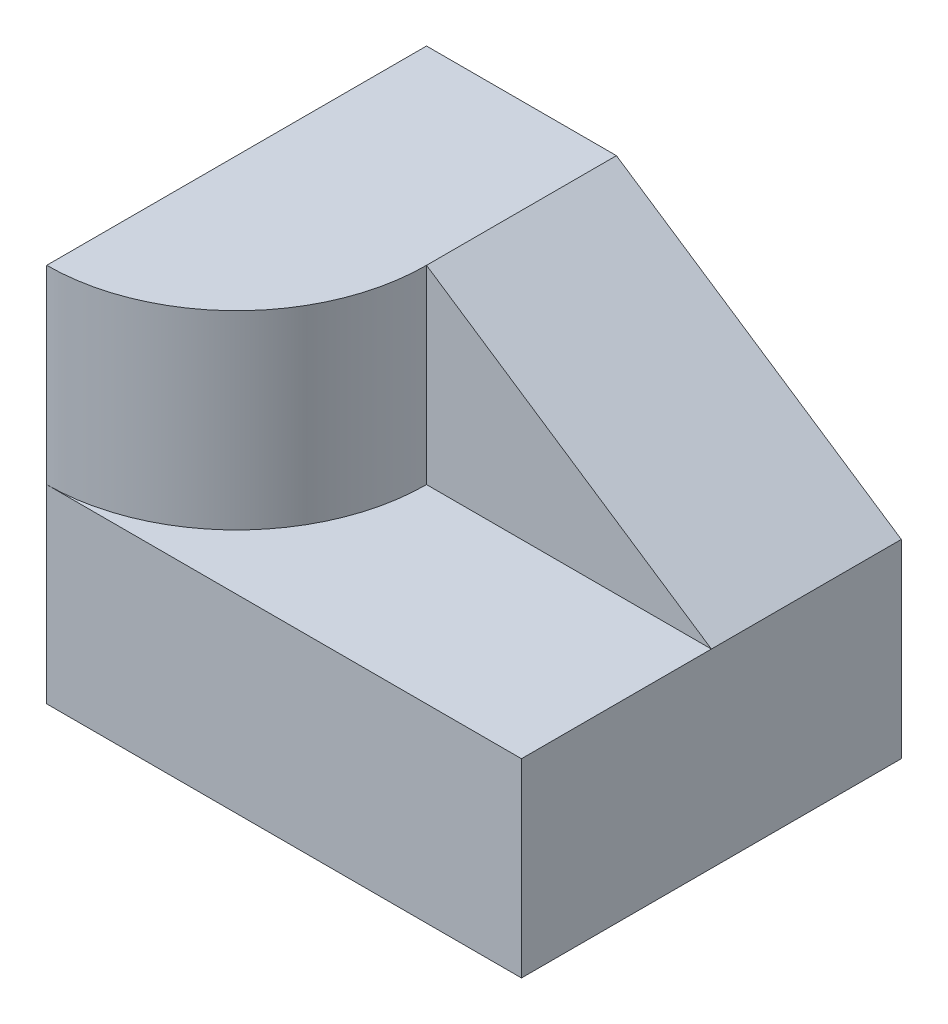
from build123d import *

# Parameters (mm, degrees)
SKETCH_1_W          = 25
SKETCH_1_H          = 20
EXTRUDE_1_DEPTH     = 10
EXTRUDE_2_DEPTH     = 20
CUT_EXTRUDE_1_DEPTH = 20
SCALE_1_SCALE       = 0.2


with BuildPart() as part:
    # 草圖1 → 填料-伸長1 (new body)
    with BuildSketch(Plane(origin=(0, 0, 0), x_dir=(1, 0, 0), z_dir=(0, 1, 0))):
        Rectangle(SKETCH_1_W, SKETCH_1_H)
    extrude(amount=EXTRUDE_1_DEPTH)

    # 草圖1<3> → 填料-伸長2 (add)
    with BuildSketch(Plane(origin=(0, 0, 0), x_dir=(1, 0, 0), z_dir=(0, 1, 0))):
        with BuildLine():
            Line((-12.5, 10), (-12.5, -10))
            ThreePointArc((-12.5, -10), (-5.428932188, -7.071067812), (-2.5, 0))
            Line((-2.5, 0), (12.5, 0))
            Line((12.5, 0), (12.5, 10))
            Line((12.5, 10), (-12.5, 10))
        make_face()
    extrude(amount=EXTRUDE_2_DEPTH)

    # 草圖2 → 除料-伸長1 (cut)
    with BuildSketch(Plane.XY):
        Polygon((-2.5, 20), (12.5, 10), (12.5, 20), align=None)
    extrude(amount=-CUT_EXTRUDE_1_DEPTH, mode=Mode.SUBTRACT)


with BuildPart() as part_1:
    # 縮放比例1: scaled about (-1.606967999, 8.198766822, -0.718829523)
    add(part.part.scale(SCALE_1_SCALE).moved(Location((-1.285574399, 6.559013458, -0.575063618))))


solid = part_1.part
